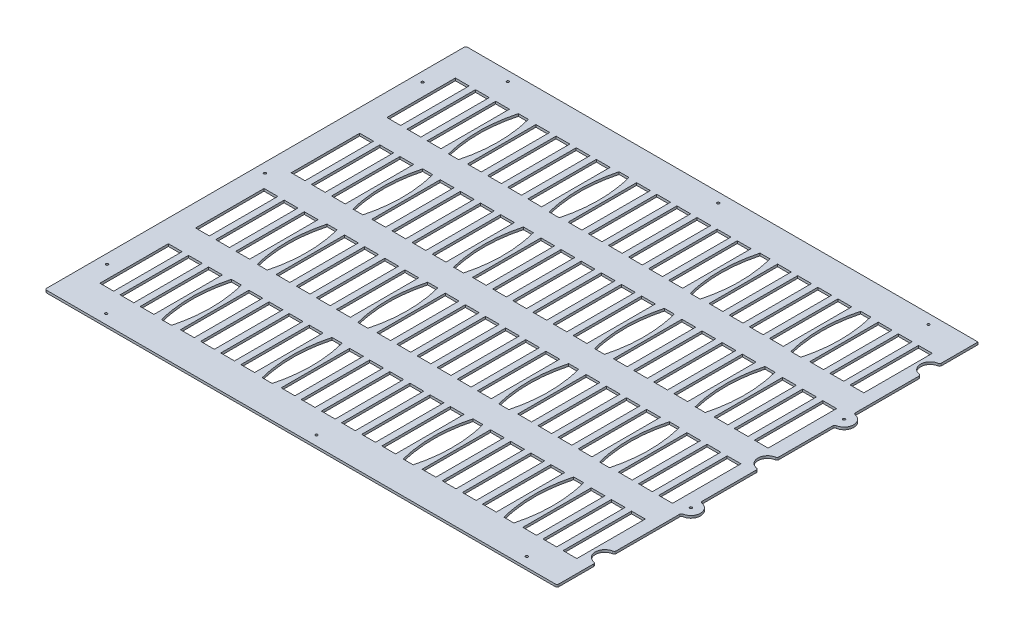
from build123d import *

# Parameters (mm, degrees)
BOSS_EXTRUDE1_DEPTH          = 3.175
SKETCH23_W                   = 18.288
SKETCH23_H                   = 90.932
CUT_EXTRUDE7_DEPTH           = 4.175
LPATTERN1_COUNT              = 24
LPATTERN1_PITCH              = 26.74731252
LPATTERN2_COUNT              = 4
LPATTERN2_PITCH              = 127.0762
LPATTERN2_COPY_1_SKETCH_W    = 18.288
LPATTERN2_COPY_1_SKETCH_H    = 90.932
LPATTERN2_COPY_1_DEPTH       = 4.175
LPATTERN2_COPY_2_SKETCH_W    = 18.288
LPATTERN2_COPY_2_SKETCH_H    = 90.932
LPATTERN2_COPY_2_DEPTH       = 4.175
LPATTERN2_COPY_3_SKETCH_W    = 18.288
LPATTERN2_COPY_3_SKETCH_H    = 90.932
LPATTERN2_COPY_3_DEPTH       = 4.175
LPATTERN2_COPY_4_SKETCH_W    = 18.288
LPATTERN2_COPY_4_SKETCH_H    = 90.932
LPATTERN2_COPY_4_DEPTH       = 4.175
LPATTERN2_COPY_5_SKETCH_W    = 18.288
LPATTERN2_COPY_5_SKETCH_H    = 90.932
LPATTERN2_COPY_5_DEPTH       = 4.175
LPATTERN2_COPY_6_SKETCH_W    = 18.288
LPATTERN2_COPY_6_SKETCH_H    = 90.932
LPATTERN2_COPY_6_DEPTH       = 4.175
LPATTERN2_COPY_7_SKETCH_W    = 18.288
LPATTERN2_COPY_7_SKETCH_H    = 90.932
LPATTERN2_COPY_7_DEPTH       = 4.175
LPATTERN2_COPY_8_SKETCH_W    = 18.288
LPATTERN2_COPY_8_SKETCH_H    = 90.932
LPATTERN2_COPY_8_DEPTH       = 4.175
LPATTERN2_COPY_9_SKETCH_W    = 18.288
LPATTERN2_COPY_9_SKETCH_H    = 90.932
LPATTERN2_COPY_9_DEPTH       = 4.175
LPATTERN2_COPY_10_SKETCH_W   = 18.288
LPATTERN2_COPY_10_SKETCH_H   = 90.932
LPATTERN2_COPY_10_DEPTH      = 4.175
LPATTERN2_COPY_11_SKETCH_W   = 18.288
LPATTERN2_COPY_11_SKETCH_H   = 90.932
LPATTERN2_COPY_11_DEPTH      = 4.175
LPATTERN2_COPY_12_SKETCH_W   = 18.288
LPATTERN2_COPY_12_SKETCH_H   = 90.932
LPATTERN2_COPY_12_DEPTH      = 4.175
LPATTERN2_COPY_13_SKETCH_W   = 18.288
LPATTERN2_COPY_13_SKETCH_H   = 90.932
LPATTERN2_COPY_13_DEPTH      = 4.175
LPATTERN2_COPY_14_SKETCH_W   = 18.288
LPATTERN2_COPY_14_SKETCH_H   = 90.932
LPATTERN2_COPY_14_DEPTH      = 4.175
LPATTERN2_COPY_15_SKETCH_W   = 18.288
LPATTERN2_COPY_15_SKETCH_H   = 90.932
LPATTERN2_COPY_15_DEPTH      = 4.175
LPATTERN2_COPY_16_SKETCH_W   = 18.288
LPATTERN2_COPY_16_SKETCH_H   = 90.932
LPATTERN2_COPY_16_DEPTH      = 4.175
LPATTERN2_COPY_17_SKETCH_W   = 18.288
LPATTERN2_COPY_17_SKETCH_H   = 90.932
LPATTERN2_COPY_17_DEPTH      = 4.175
LPATTERN2_COPY_18_SKETCH_W   = 18.288
LPATTERN2_COPY_18_SKETCH_H   = 90.932
LPATTERN2_COPY_18_DEPTH      = 4.175
LPATTERN2_COPY_19_SKETCH_W   = 18.288
LPATTERN2_COPY_19_SKETCH_H   = 90.932
LPATTERN2_COPY_19_DEPTH      = 4.175
LPATTERN2_COPY_20_SKETCH_W   = 18.288
LPATTERN2_COPY_20_SKETCH_H   = 90.932
LPATTERN2_COPY_20_DEPTH      = 4.175
LPATTERN2_COPY_21_SKETCH_W   = 18.288
LPATTERN2_COPY_21_SKETCH_H   = 90.932
LPATTERN2_COPY_21_DEPTH      = 4.175
LPATTERN2_COPY_22_SKETCH_W   = 18.288
LPATTERN2_COPY_22_SKETCH_H   = 90.932
LPATTERN2_COPY_22_DEPTH      = 4.175
LPATTERN2_COPY_23_SKETCH_W   = 18.288
LPATTERN2_COPY_23_SKETCH_H   = 90.932
LPATTERN2_COPY_23_DEPTH      = 4.175
LPATTERN2_COPY_24_SKETCH_W   = 18.288
LPATTERN2_COPY_24_SKETCH_H   = 90.932
LPATTERN2_COPY_24_DEPTH      = 4.175
LPATTERN2_COPY_25_SKETCH_W   = 18.288
LPATTERN2_COPY_25_SKETCH_H   = 90.932
LPATTERN2_COPY_25_DEPTH      = 4.175
LPATTERN2_COPY_26_SKETCH_W   = 18.288
LPATTERN2_COPY_26_SKETCH_H   = 90.932
LPATTERN2_COPY_26_DEPTH      = 4.175
LPATTERN2_COPY_27_SKETCH_W   = 18.288
LPATTERN2_COPY_27_SKETCH_H   = 90.932
LPATTERN2_COPY_27_DEPTH      = 4.175
LPATTERN2_COPY_28_SKETCH_W   = 18.288
LPATTERN2_COPY_28_SKETCH_H   = 90.932
LPATTERN2_COPY_28_DEPTH      = 4.175
LPATTERN2_COPY_29_SKETCH_W   = 18.288
LPATTERN2_COPY_29_SKETCH_H   = 90.932
LPATTERN2_COPY_29_DEPTH      = 4.175
LPATTERN2_COPY_30_SKETCH_W   = 18.288
LPATTERN2_COPY_30_SKETCH_H   = 90.932
LPATTERN2_COPY_30_DEPTH      = 4.175
LPATTERN2_COPY_31_SKETCH_W   = 18.288
LPATTERN2_COPY_31_SKETCH_H   = 90.932
LPATTERN2_COPY_31_DEPTH      = 4.175
LPATTERN2_COPY_32_SKETCH_W   = 18.288
LPATTERN2_COPY_32_SKETCH_H   = 90.932
LPATTERN2_COPY_32_DEPTH      = 4.175
LPATTERN2_COPY_33_SKETCH_W   = 18.288
LPATTERN2_COPY_33_SKETCH_H   = 90.932
LPATTERN2_COPY_33_DEPTH      = 4.175
LPATTERN2_COPY_34_SKETCH_W   = 18.288
LPATTERN2_COPY_34_SKETCH_H   = 90.932
LPATTERN2_COPY_34_DEPTH      = 4.175
LPATTERN2_COPY_35_SKETCH_W   = 18.288
LPATTERN2_COPY_35_SKETCH_H   = 90.932
LPATTERN2_COPY_35_DEPTH      = 4.175
LPATTERN2_COPY_36_SKETCH_W   = 18.288
LPATTERN2_COPY_36_SKETCH_H   = 90.932
LPATTERN2_COPY_36_DEPTH      = 4.175
LPATTERN2_COPY_37_SKETCH_W   = 18.288
LPATTERN2_COPY_37_SKETCH_H   = 90.932
LPATTERN2_COPY_37_DEPTH      = 4.175
LPATTERN2_COPY_38_SKETCH_W   = 18.288
LPATTERN2_COPY_38_SKETCH_H   = 90.932
LPATTERN2_COPY_38_DEPTH      = 4.175
LPATTERN2_COPY_39_SKETCH_W   = 18.288
LPATTERN2_COPY_39_SKETCH_H   = 90.932
LPATTERN2_COPY_39_DEPTH      = 4.175
LPATTERN2_COPY_40_SKETCH_W   = 18.288
LPATTERN2_COPY_40_SKETCH_H   = 90.932
LPATTERN2_COPY_40_DEPTH      = 4.175
LPATTERN2_COPY_41_SKETCH_W   = 18.288
LPATTERN2_COPY_41_SKETCH_H   = 90.932
LPATTERN2_COPY_41_DEPTH      = 4.175
LPATTERN2_COPY_42_SKETCH_W   = 18.288
LPATTERN2_COPY_42_SKETCH_H   = 90.932
LPATTERN2_COPY_42_DEPTH      = 4.175
LPATTERN2_COPY_43_SKETCH_W   = 18.288
LPATTERN2_COPY_43_SKETCH_H   = 90.932
LPATTERN2_COPY_43_DEPTH      = 4.175
LPATTERN2_COPY_44_SKETCH_W   = 18.288
LPATTERN2_COPY_44_SKETCH_H   = 90.932
LPATTERN2_COPY_44_DEPTH      = 4.175
LPATTERN2_COPY_45_SKETCH_W   = 18.288
LPATTERN2_COPY_45_SKETCH_H   = 90.932
LPATTERN2_COPY_45_DEPTH      = 4.175
LPATTERN2_COPY_46_SKETCH_W   = 18.288
LPATTERN2_COPY_46_SKETCH_H   = 90.932
LPATTERN2_COPY_46_DEPTH      = 4.175
LPATTERN2_COPY_47_SKETCH_W   = 18.288
LPATTERN2_COPY_47_SKETCH_H   = 90.932
LPATTERN2_COPY_47_DEPTH      = 4.175
LPATTERN2_COPY_48_SKETCH_W   = 18.288
LPATTERN2_COPY_48_SKETCH_H   = 90.932
LPATTERN2_COPY_48_DEPTH      = 4.175
LPATTERN2_COPY_49_SKETCH_W   = 18.288
LPATTERN2_COPY_49_SKETCH_H   = 90.932
LPATTERN2_COPY_49_DEPTH      = 4.175
LPATTERN2_COPY_50_SKETCH_W   = 18.288
LPATTERN2_COPY_50_SKETCH_H   = 90.932
LPATTERN2_COPY_50_DEPTH      = 4.175
LPATTERN2_COPY_51_SKETCH_W   = 18.288
LPATTERN2_COPY_51_SKETCH_H   = 90.932
LPATTERN2_COPY_51_DEPTH      = 4.175
LPATTERN2_COPY_52_SKETCH_W   = 18.288
LPATTERN2_COPY_52_SKETCH_H   = 90.932
LPATTERN2_COPY_52_DEPTH      = 4.175
LPATTERN2_COPY_53_SKETCH_W   = 18.288
LPATTERN2_COPY_53_SKETCH_H   = 90.932
LPATTERN2_COPY_53_DEPTH      = 4.175
LPATTERN2_COPY_54_SKETCH_W   = 18.288
LPATTERN2_COPY_54_SKETCH_H   = 90.932
LPATTERN2_COPY_54_DEPTH      = 4.175
LPATTERN2_COPY_55_SKETCH_W   = 18.288
LPATTERN2_COPY_55_SKETCH_H   = 90.932
LPATTERN2_COPY_55_DEPTH      = 4.175
LPATTERN2_COPY_56_SKETCH_W   = 18.288
LPATTERN2_COPY_56_SKETCH_H   = 90.932
LPATTERN2_COPY_56_DEPTH      = 4.175
LPATTERN2_COPY_57_SKETCH_W   = 18.288
LPATTERN2_COPY_57_SKETCH_H   = 90.932
LPATTERN2_COPY_57_DEPTH      = 4.175
CUT_EXTRUDE8_DEPTH           = 4.175
LPATTERN3_COUNT              = 2
LPATTERN3_PITCH              = 320.96775024
LPATTERN3_COUNT_DIR2         = 4
LPATTERN3_PITCH_DIR2         = 127.0762
FILLET1_R                    = 2.54
F_1_8_0_125_DIAMETER_HOLE1_D = 3.175


with BuildPart() as part:
    # Sketch1 → Boss-Extrude1 (new body)
    with BuildSketch(Plane(origin=(0, 0, 0), x_dir=(1, 0, 0), z_dir=(0, 1, 0))):
        with BuildLine():
            Line((-340.1822, -279.5524), (340.1822, -279.5524))
            Line((340.1822, -279.5524), (340.1822, -228.7524))
            ThreePointArc((340.1822, -228.7524), (327.4822, -216.0524), (340.1822, -203.3524))
            Line((340.1822, -203.3524), (340.1822, -114.4524))
            ThreePointArc((340.1822, -114.4524), (352.8822, -101.7524), (340.1822, -89.0524))
            Line((340.1822, -89.0524), (340.1822, -12.7))
            ThreePointArc((340.1822, -12.7), (327.4822, 0), (340.1822, 12.7))
            Line((340.1822, 12.7), (340.1822, 89.0524))
            ThreePointArc((340.1822, 89.0524), (352.8822, 101.7524), (340.1822, 114.4524))
            Line((340.1822, 114.4524), (340.1822, 203.3524))
            ThreePointArc((340.1822, 203.3524), (327.4822, 216.0524), (340.1822, 228.7524))
            Line((340.1822, 228.7524), (340.1822, 279.5524))
            Line((340.1822, 279.5524), (-340.1822, 279.5524))
            Line((-340.1822, 279.5524), (-340.1822, -279.5524))
        make_face()
    extrude(amount=BOSS_EXTRUDE1_DEPTH)

    # Sketch23 → Cut-Extrude7 (cut, through all)
    with BuildSketch(Plane(origin=(0, 3.175, 0), x_dir=(1, 0, 0), z_dir=(0, 1, 0))):
        with Locations((313.7408, -190.5762)):
            Rectangle(SKETCH23_W, SKETCH23_H)
    cut_extrude7 = extrude(amount=-CUT_EXTRUDE7_DEPTH, mode=Mode.SUBTRACT)

    # LPattern1: Cut-Extrude7 ×24, 4 skipped
    with Locations(*[(-i * LPATTERN1_PITCH, 0, 0) for i in range(1, LPATTERN1_COUNT) if i not in (3, 8, 15, 20)]):
        add(cut_extrude7, mode=Mode.SUBTRACT)

    # LPattern2: Cut-Extrude7 ×4
    with Locations(*[(0, 0, -i * LPATTERN2_PITCH) for i in range(1, LPATTERN2_COUNT)]):
        add(cut_extrude7, mode=Mode.SUBTRACT)

    # LPattern2 copy 1 sketch → LPattern2 copy 1 (cut, through all)
    with BuildSketch(Plane(origin=(-26.74731252, 3.175, -127.0762), x_dir=(1, 0, 0), z_dir=(0, 1, 0))):
        with Locations((313.7408, -190.5762)):
            Rectangle(LPATTERN2_COPY_1_SKETCH_W, LPATTERN2_COPY_1_SKETCH_H)
    extrude(amount=-LPATTERN2_COPY_1_DEPTH, mode=Mode.SUBTRACT)

    # LPattern2 copy 2 sketch → LPattern2 copy 2 (cut, through all)
    with BuildSketch(Plane(origin=(-26.74731252, 3.175, -254.1524), x_dir=(1, 0, 0), z_dir=(0, 1, 0))):
        with Locations((313.7408, -190.5762)):
            Rectangle(LPATTERN2_COPY_2_SKETCH_W, LPATTERN2_COPY_2_SKETCH_H)
    extrude(amount=-LPATTERN2_COPY_2_DEPTH, mode=Mode.SUBTRACT)

    # LPattern2 copy 3 sketch → LPattern2 copy 3 (cut, through all)
    with BuildSketch(Plane(origin=(-26.74731252, 3.175, -381.2286), x_dir=(1, 0, 0), z_dir=(0, 1, 0))):
        with Locations((313.7408, -190.5762)):
            Rectangle(LPATTERN2_COPY_3_SKETCH_W, LPATTERN2_COPY_3_SKETCH_H)
    extrude(amount=-LPATTERN2_COPY_3_DEPTH, mode=Mode.SUBTRACT)

    # LPattern2 copy 4 sketch → LPattern2 copy 4 (cut, through all)
    with BuildSketch(Plane(origin=(-53.49462504, 3.175, -127.0762), x_dir=(1, 0, 0), z_dir=(0, 1, 0))):
        with Locations((313.7408, -190.5762)):
            Rectangle(LPATTERN2_COPY_4_SKETCH_W, LPATTERN2_COPY_4_SKETCH_H)
    extrude(amount=-LPATTERN2_COPY_4_DEPTH, mode=Mode.SUBTRACT)

    # LPattern2 copy 5 sketch → LPattern2 copy 5 (cut, through all)
    with BuildSketch(Plane(origin=(-53.49462504, 3.175, -254.1524), x_dir=(1, 0, 0), z_dir=(0, 1, 0))):
        with Locations((313.7408, -190.5762)):
            Rectangle(LPATTERN2_COPY_5_SKETCH_W, LPATTERN2_COPY_5_SKETCH_H)
    extrude(amount=-LPATTERN2_COPY_5_DEPTH, mode=Mode.SUBTRACT)

    # LPattern2 copy 6 sketch → LPattern2 copy 6 (cut, through all)
    with BuildSketch(Plane(origin=(-53.49462504, 3.175, -381.2286), x_dir=(1, 0, 0), z_dir=(0, 1, 0))):
        with Locations((313.7408, -190.5762)):
            Rectangle(LPATTERN2_COPY_6_SKETCH_W, LPATTERN2_COPY_6_SKETCH_H)
    extrude(amount=-LPATTERN2_COPY_6_DEPTH, mode=Mode.SUBTRACT)

    # LPattern2 copy 7 sketch → LPattern2 copy 7 (cut, through all)
    with BuildSketch(Plane(origin=(-106.98925008, 3.175, -127.0762), x_dir=(1, 0, 0), z_dir=(0, 1, 0))):
        with Locations((313.7408, -190.5762)):
            Rectangle(LPATTERN2_COPY_7_SKETCH_W, LPATTERN2_COPY_7_SKETCH_H)
    extrude(amount=-LPATTERN2_COPY_7_DEPTH, mode=Mode.SUBTRACT)

    # LPattern2 copy 8 sketch → LPattern2 copy 8 (cut, through all)
    with BuildSketch(Plane(origin=(-106.98925008, 3.175, -254.1524), x_dir=(1, 0, 0), z_dir=(0, 1, 0))):
        with Locations((313.7408, -190.5762)):
            Rectangle(LPATTERN2_COPY_8_SKETCH_W, LPATTERN2_COPY_8_SKETCH_H)
    extrude(amount=-LPATTERN2_COPY_8_DEPTH, mode=Mode.SUBTRACT)

    # LPattern2 copy 9 sketch → LPattern2 copy 9 (cut, through all)
    with BuildSketch(Plane(origin=(-106.98925008, 3.175, -381.2286), x_dir=(1, 0, 0), z_dir=(0, 1, 0))):
        with Locations((313.7408, -190.5762)):
            Rectangle(LPATTERN2_COPY_9_SKETCH_W, LPATTERN2_COPY_9_SKETCH_H)
    extrude(amount=-LPATTERN2_COPY_9_DEPTH, mode=Mode.SUBTRACT)

    # LPattern2 copy 10 sketch → LPattern2 copy 10 (cut, through all)
    with BuildSketch(Plane(origin=(-133.7365626, 3.175, -127.0762), x_dir=(1, 0, 0), z_dir=(0, 1, 0))):
        with Locations((313.7408, -190.5762)):
            Rectangle(LPATTERN2_COPY_10_SKETCH_W, LPATTERN2_COPY_10_SKETCH_H)
    extrude(amount=-LPATTERN2_COPY_10_DEPTH, mode=Mode.SUBTRACT)

    # LPattern2 copy 11 sketch → LPattern2 copy 11 (cut, through all)
    with BuildSketch(Plane(origin=(-133.7365626, 3.175, -254.1524), x_dir=(1, 0, 0), z_dir=(0, 1, 0))):
        with Locations((313.7408, -190.5762)):
            Rectangle(LPATTERN2_COPY_11_SKETCH_W, LPATTERN2_COPY_11_SKETCH_H)
    extrude(amount=-LPATTERN2_COPY_11_DEPTH, mode=Mode.SUBTRACT)

    # LPattern2 copy 12 sketch → LPattern2 copy 12 (cut, through all)
    with BuildSketch(Plane(origin=(-133.7365626, 3.175, -381.2286), x_dir=(1, 0, 0), z_dir=(0, 1, 0))):
        with Locations((313.7408, -190.5762)):
            Rectangle(LPATTERN2_COPY_12_SKETCH_W, LPATTERN2_COPY_12_SKETCH_H)
    extrude(amount=-LPATTERN2_COPY_12_DEPTH, mode=Mode.SUBTRACT)

    # LPattern2 copy 13 sketch → LPattern2 copy 13 (cut, through all)
    with BuildSketch(Plane(origin=(-160.48387512, 3.175, -127.0762), x_dir=(1, 0, 0), z_dir=(0, 1, 0))):
        with Locations((313.7408, -190.5762)):
            Rectangle(LPATTERN2_COPY_13_SKETCH_W, LPATTERN2_COPY_13_SKETCH_H)
    extrude(amount=-LPATTERN2_COPY_13_DEPTH, mode=Mode.SUBTRACT)

    # LPattern2 copy 14 sketch → LPattern2 copy 14 (cut, through all)
    with BuildSketch(Plane(origin=(-160.48387512, 3.175, -254.1524), x_dir=(1, 0, 0), z_dir=(0, 1, 0))):
        with Locations((313.7408, -190.5762)):
            Rectangle(LPATTERN2_COPY_14_SKETCH_W, LPATTERN2_COPY_14_SKETCH_H)
    extrude(amount=-LPATTERN2_COPY_14_DEPTH, mode=Mode.SUBTRACT)

    # LPattern2 copy 15 sketch → LPattern2 copy 15 (cut, through all)
    with BuildSketch(Plane(origin=(-160.48387512, 3.175, -381.2286), x_dir=(1, 0, 0), z_dir=(0, 1, 0))):
        with Locations((313.7408, -190.5762)):
            Rectangle(LPATTERN2_COPY_15_SKETCH_W, LPATTERN2_COPY_15_SKETCH_H)
    extrude(amount=-LPATTERN2_COPY_15_DEPTH, mode=Mode.SUBTRACT)

    # LPattern2 copy 16 sketch → LPattern2 copy 16 (cut, through all)
    with BuildSketch(Plane(origin=(-187.23118764, 3.175, -127.0762), x_dir=(1, 0, 0), z_dir=(0, 1, 0))):
        with Locations((313.7408, -190.5762)):
            Rectangle(LPATTERN2_COPY_16_SKETCH_W, LPATTERN2_COPY_16_SKETCH_H)
    extrude(amount=-LPATTERN2_COPY_16_DEPTH, mode=Mode.SUBTRACT)

    # LPattern2 copy 17 sketch → LPattern2 copy 17 (cut, through all)
    with BuildSketch(Plane(origin=(-187.23118764, 3.175, -254.1524), x_dir=(1, 0, 0), z_dir=(0, 1, 0))):
        with Locations((313.7408, -190.5762)):
            Rectangle(LPATTERN2_COPY_17_SKETCH_W, LPATTERN2_COPY_17_SKETCH_H)
    extrude(amount=-LPATTERN2_COPY_17_DEPTH, mode=Mode.SUBTRACT)

    # LPattern2 copy 18 sketch → LPattern2 copy 18 (cut, through all)
    with BuildSketch(Plane(origin=(-187.23118764, 3.175, -381.2286), x_dir=(1, 0, 0), z_dir=(0, 1, 0))):
        with Locations((313.7408, -190.5762)):
            Rectangle(LPATTERN2_COPY_18_SKETCH_W, LPATTERN2_COPY_18_SKETCH_H)
    extrude(amount=-LPATTERN2_COPY_18_DEPTH, mode=Mode.SUBTRACT)

    # LPattern2 copy 19 sketch → LPattern2 copy 19 (cut, through all)
    with BuildSketch(Plane(origin=(-240.72581268, 3.175, -127.0762), x_dir=(1, 0, 0), z_dir=(0, 1, 0))):
        with Locations((313.7408, -190.5762)):
            Rectangle(LPATTERN2_COPY_19_SKETCH_W, LPATTERN2_COPY_19_SKETCH_H)
    extrude(amount=-LPATTERN2_COPY_19_DEPTH, mode=Mode.SUBTRACT)

    # LPattern2 copy 20 sketch → LPattern2 copy 20 (cut, through all)
    with BuildSketch(Plane(origin=(-240.72581268, 3.175, -254.1524), x_dir=(1, 0, 0), z_dir=(0, 1, 0))):
        with Locations((313.7408, -190.5762)):
            Rectangle(LPATTERN2_COPY_20_SKETCH_W, LPATTERN2_COPY_20_SKETCH_H)
    extrude(amount=-LPATTERN2_COPY_20_DEPTH, mode=Mode.SUBTRACT)

    # LPattern2 copy 21 sketch → LPattern2 copy 21 (cut, through all)
    with BuildSketch(Plane(origin=(-240.72581268, 3.175, -381.2286), x_dir=(1, 0, 0), z_dir=(0, 1, 0))):
        with Locations((313.7408, -190.5762)):
            Rectangle(LPATTERN2_COPY_21_SKETCH_W, LPATTERN2_COPY_21_SKETCH_H)
    extrude(amount=-LPATTERN2_COPY_21_DEPTH, mode=Mode.SUBTRACT)

    # LPattern2 copy 22 sketch → LPattern2 copy 22 (cut, through all)
    with BuildSketch(Plane(origin=(-267.4731252, 3.175, -127.0762), x_dir=(1, 0, 0), z_dir=(0, 1, 0))):
        with Locations((313.7408, -190.5762)):
            Rectangle(LPATTERN2_COPY_22_SKETCH_W, LPATTERN2_COPY_22_SKETCH_H)
    extrude(amount=-LPATTERN2_COPY_22_DEPTH, mode=Mode.SUBTRACT)

    # LPattern2 copy 23 sketch → LPattern2 copy 23 (cut, through all)
    with BuildSketch(Plane(origin=(-267.4731252, 3.175, -254.1524), x_dir=(1, 0, 0), z_dir=(0, 1, 0))):
        with Locations((313.7408, -190.5762)):
            Rectangle(LPATTERN2_COPY_23_SKETCH_W, LPATTERN2_COPY_23_SKETCH_H)
    extrude(amount=-LPATTERN2_COPY_23_DEPTH, mode=Mode.SUBTRACT)

    # LPattern2 copy 24 sketch → LPattern2 copy 24 (cut, through all)
    with BuildSketch(Plane(origin=(-267.4731252, 3.175, -381.2286), x_dir=(1, 0, 0), z_dir=(0, 1, 0))):
        with Locations((313.7408, -190.5762)):
            Rectangle(LPATTERN2_COPY_24_SKETCH_W, LPATTERN2_COPY_24_SKETCH_H)
    extrude(amount=-LPATTERN2_COPY_24_DEPTH, mode=Mode.SUBTRACT)

    # LPattern2 copy 25 sketch → LPattern2 copy 25 (cut, through all)
    with BuildSketch(Plane(origin=(-294.22043772, 3.175, -127.0762), x_dir=(1, 0, 0), z_dir=(0, 1, 0))):
        with Locations((313.7408, -190.5762)):
            Rectangle(LPATTERN2_COPY_25_SKETCH_W, LPATTERN2_COPY_25_SKETCH_H)
    extrude(amount=-LPATTERN2_COPY_25_DEPTH, mode=Mode.SUBTRACT)

    # LPattern2 copy 26 sketch → LPattern2 copy 26 (cut, through all)
    with BuildSketch(Plane(origin=(-294.22043772, 3.175, -254.1524), x_dir=(1, 0, 0), z_dir=(0, 1, 0))):
        with Locations((313.7408, -190.5762)):
            Rectangle(LPATTERN2_COPY_26_SKETCH_W, LPATTERN2_COPY_26_SKETCH_H)
    extrude(amount=-LPATTERN2_COPY_26_DEPTH, mode=Mode.SUBTRACT)

    # LPattern2 copy 27 sketch → LPattern2 copy 27 (cut, through all)
    with BuildSketch(Plane(origin=(-294.22043772, 3.175, -381.2286), x_dir=(1, 0, 0), z_dir=(0, 1, 0))):
        with Locations((313.7408, -190.5762)):
            Rectangle(LPATTERN2_COPY_27_SKETCH_W, LPATTERN2_COPY_27_SKETCH_H)
    extrude(amount=-LPATTERN2_COPY_27_DEPTH, mode=Mode.SUBTRACT)

    # LPattern2 copy 28 sketch → LPattern2 copy 28 (cut, through all)
    with BuildSketch(Plane(origin=(-320.96775024, 3.175, -127.0762), x_dir=(1, 0, 0), z_dir=(0, 1, 0))):
        with Locations((313.7408, -190.5762)):
            Rectangle(LPATTERN2_COPY_28_SKETCH_W, LPATTERN2_COPY_28_SKETCH_H)
    extrude(amount=-LPATTERN2_COPY_28_DEPTH, mode=Mode.SUBTRACT)

    # LPattern2 copy 29 sketch → LPattern2 copy 29 (cut, through all)
    with BuildSketch(Plane(origin=(-320.96775024, 3.175, -254.1524), x_dir=(1, 0, 0), z_dir=(0, 1, 0))):
        with Locations((313.7408, -190.5762)):
            Rectangle(LPATTERN2_COPY_29_SKETCH_W, LPATTERN2_COPY_29_SKETCH_H)
    extrude(amount=-LPATTERN2_COPY_29_DEPTH, mode=Mode.SUBTRACT)

    # LPattern2 copy 30 sketch → LPattern2 copy 30 (cut, through all)
    with BuildSketch(Plane(origin=(-320.96775024, 3.175, -381.2286), x_dir=(1, 0, 0), z_dir=(0, 1, 0))):
        with Locations((313.7408, -190.5762)):
            Rectangle(LPATTERN2_COPY_30_SKETCH_W, LPATTERN2_COPY_30_SKETCH_H)
    extrude(amount=-LPATTERN2_COPY_30_DEPTH, mode=Mode.SUBTRACT)

    # LPattern2 copy 31 sketch → LPattern2 copy 31 (cut, through all)
    with BuildSketch(Plane(origin=(-347.71506276, 3.175, -127.0762), x_dir=(1, 0, 0), z_dir=(0, 1, 0))):
        with Locations((313.7408, -190.5762)):
            Rectangle(LPATTERN2_COPY_31_SKETCH_W, LPATTERN2_COPY_31_SKETCH_H)
    extrude(amount=-LPATTERN2_COPY_31_DEPTH, mode=Mode.SUBTRACT)

    # LPattern2 copy 32 sketch → LPattern2 copy 32 (cut, through all)
    with BuildSketch(Plane(origin=(-347.71506276, 3.175, -254.1524), x_dir=(1, 0, 0), z_dir=(0, 1, 0))):
        with Locations((313.7408, -190.5762)):
            Rectangle(LPATTERN2_COPY_32_SKETCH_W, LPATTERN2_COPY_32_SKETCH_H)
    extrude(amount=-LPATTERN2_COPY_32_DEPTH, mode=Mode.SUBTRACT)

    # LPattern2 copy 33 sketch → LPattern2 copy 33 (cut, through all)
    with BuildSketch(Plane(origin=(-347.71506276, 3.175, -381.2286), x_dir=(1, 0, 0), z_dir=(0, 1, 0))):
        with Locations((313.7408, -190.5762)):
            Rectangle(LPATTERN2_COPY_33_SKETCH_W, LPATTERN2_COPY_33_SKETCH_H)
    extrude(amount=-LPATTERN2_COPY_33_DEPTH, mode=Mode.SUBTRACT)

    # LPattern2 copy 34 sketch → LPattern2 copy 34 (cut, through all)
    with BuildSketch(Plane(origin=(-374.46237528, 3.175, -127.0762), x_dir=(1, 0, 0), z_dir=(0, 1, 0))):
        with Locations((313.7408, -190.5762)):
            Rectangle(LPATTERN2_COPY_34_SKETCH_W, LPATTERN2_COPY_34_SKETCH_H)
    extrude(amount=-LPATTERN2_COPY_34_DEPTH, mode=Mode.SUBTRACT)

    # LPattern2 copy 35 sketch → LPattern2 copy 35 (cut, through all)
    with BuildSketch(Plane(origin=(-374.46237528, 3.175, -254.1524), x_dir=(1, 0, 0), z_dir=(0, 1, 0))):
        with Locations((313.7408, -190.5762)):
            Rectangle(LPATTERN2_COPY_35_SKETCH_W, LPATTERN2_COPY_35_SKETCH_H)
    extrude(amount=-LPATTERN2_COPY_35_DEPTH, mode=Mode.SUBTRACT)

    # LPattern2 copy 36 sketch → LPattern2 copy 36 (cut, through all)
    with BuildSketch(Plane(origin=(-374.46237528, 3.175, -381.2286), x_dir=(1, 0, 0), z_dir=(0, 1, 0))):
        with Locations((313.7408, -190.5762)):
            Rectangle(LPATTERN2_COPY_36_SKETCH_W, LPATTERN2_COPY_36_SKETCH_H)
    extrude(amount=-LPATTERN2_COPY_36_DEPTH, mode=Mode.SUBTRACT)

    # LPattern2 copy 37 sketch → LPattern2 copy 37 (cut, through all)
    with BuildSketch(Plane(origin=(-427.95700032, 3.175, -127.0762), x_dir=(1, 0, 0), z_dir=(0, 1, 0))):
        with Locations((313.7408, -190.5762)):
            Rectangle(LPATTERN2_COPY_37_SKETCH_W, LPATTERN2_COPY_37_SKETCH_H)
    extrude(amount=-LPATTERN2_COPY_37_DEPTH, mode=Mode.SUBTRACT)

    # LPattern2 copy 38 sketch → LPattern2 copy 38 (cut, through all)
    with BuildSketch(Plane(origin=(-427.95700032, 3.175, -254.1524), x_dir=(1, 0, 0), z_dir=(0, 1, 0))):
        with Locations((313.7408, -190.5762)):
            Rectangle(LPATTERN2_COPY_38_SKETCH_W, LPATTERN2_COPY_38_SKETCH_H)
    extrude(amount=-LPATTERN2_COPY_38_DEPTH, mode=Mode.SUBTRACT)

    # LPattern2 copy 39 sketch → LPattern2 copy 39 (cut, through all)
    with BuildSketch(Plane(origin=(-427.95700032, 3.175, -381.2286), x_dir=(1, 0, 0), z_dir=(0, 1, 0))):
        with Locations((313.7408, -190.5762)):
            Rectangle(LPATTERN2_COPY_39_SKETCH_W, LPATTERN2_COPY_39_SKETCH_H)
    extrude(amount=-LPATTERN2_COPY_39_DEPTH, mode=Mode.SUBTRACT)

    # LPattern2 copy 40 sketch → LPattern2 copy 40 (cut, through all)
    with BuildSketch(Plane(origin=(-454.70431284, 3.175, -127.0762), x_dir=(1, 0, 0), z_dir=(0, 1, 0))):
        with Locations((313.7408, -190.5762)):
            Rectangle(LPATTERN2_COPY_40_SKETCH_W, LPATTERN2_COPY_40_SKETCH_H)
    extrude(amount=-LPATTERN2_COPY_40_DEPTH, mode=Mode.SUBTRACT)

    # LPattern2 copy 41 sketch → LPattern2 copy 41 (cut, through all)
    with BuildSketch(Plane(origin=(-454.70431284, 3.175, -254.1524), x_dir=(1, 0, 0), z_dir=(0, 1, 0))):
        with Locations((313.7408, -190.5762)):
            Rectangle(LPATTERN2_COPY_41_SKETCH_W, LPATTERN2_COPY_41_SKETCH_H)
    extrude(amount=-LPATTERN2_COPY_41_DEPTH, mode=Mode.SUBTRACT)

    # LPattern2 copy 42 sketch → LPattern2 copy 42 (cut, through all)
    with BuildSketch(Plane(origin=(-454.70431284, 3.175, -381.2286), x_dir=(1, 0, 0), z_dir=(0, 1, 0))):
        with Locations((313.7408, -190.5762)):
            Rectangle(LPATTERN2_COPY_42_SKETCH_W, LPATTERN2_COPY_42_SKETCH_H)
    extrude(amount=-LPATTERN2_COPY_42_DEPTH, mode=Mode.SUBTRACT)

    # LPattern2 copy 43 sketch → LPattern2 copy 43 (cut, through all)
    with BuildSketch(Plane(origin=(-481.45162536, 3.175, -127.0762), x_dir=(1, 0, 0), z_dir=(0, 1, 0))):
        with Locations((313.7408, -190.5762)):
            Rectangle(LPATTERN2_COPY_43_SKETCH_W, LPATTERN2_COPY_43_SKETCH_H)
    extrude(amount=-LPATTERN2_COPY_43_DEPTH, mode=Mode.SUBTRACT)

    # LPattern2 copy 44 sketch → LPattern2 copy 44 (cut, through all)
    with BuildSketch(Plane(origin=(-481.45162536, 3.175, -254.1524), x_dir=(1, 0, 0), z_dir=(0, 1, 0))):
        with Locations((313.7408, -190.5762)):
            Rectangle(LPATTERN2_COPY_44_SKETCH_W, LPATTERN2_COPY_44_SKETCH_H)
    extrude(amount=-LPATTERN2_COPY_44_DEPTH, mode=Mode.SUBTRACT)

    # LPattern2 copy 45 sketch → LPattern2 copy 45 (cut, through all)
    with BuildSketch(Plane(origin=(-481.45162536, 3.175, -381.2286), x_dir=(1, 0, 0), z_dir=(0, 1, 0))):
        with Locations((313.7408, -190.5762)):
            Rectangle(LPATTERN2_COPY_45_SKETCH_W, LPATTERN2_COPY_45_SKETCH_H)
    extrude(amount=-LPATTERN2_COPY_45_DEPTH, mode=Mode.SUBTRACT)

    # LPattern2 copy 46 sketch → LPattern2 copy 46 (cut, through all)
    with BuildSketch(Plane(origin=(-508.19893788, 3.175, -127.0762), x_dir=(1, 0, 0), z_dir=(0, 1, 0))):
        with Locations((313.7408, -190.5762)):
            Rectangle(LPATTERN2_COPY_46_SKETCH_W, LPATTERN2_COPY_46_SKETCH_H)
    extrude(amount=-LPATTERN2_COPY_46_DEPTH, mode=Mode.SUBTRACT)

    # LPattern2 copy 47 sketch → LPattern2 copy 47 (cut, through all)
    with BuildSketch(Plane(origin=(-508.19893788, 3.175, -254.1524), x_dir=(1, 0, 0), z_dir=(0, 1, 0))):
        with Locations((313.7408, -190.5762)):
            Rectangle(LPATTERN2_COPY_47_SKETCH_W, LPATTERN2_COPY_47_SKETCH_H)
    extrude(amount=-LPATTERN2_COPY_47_DEPTH, mode=Mode.SUBTRACT)

    # LPattern2 copy 48 sketch → LPattern2 copy 48 (cut, through all)
    with BuildSketch(Plane(origin=(-508.19893788, 3.175, -381.2286), x_dir=(1, 0, 0), z_dir=(0, 1, 0))):
        with Locations((313.7408, -190.5762)):
            Rectangle(LPATTERN2_COPY_48_SKETCH_W, LPATTERN2_COPY_48_SKETCH_H)
    extrude(amount=-LPATTERN2_COPY_48_DEPTH, mode=Mode.SUBTRACT)

    # LPattern2 copy 49 sketch → LPattern2 copy 49 (cut, through all)
    with BuildSketch(Plane(origin=(-561.69356292, 3.175, -127.0762), x_dir=(1, 0, 0), z_dir=(0, 1, 0))):
        with Locations((313.7408, -190.5762)):
            Rectangle(LPATTERN2_COPY_49_SKETCH_W, LPATTERN2_COPY_49_SKETCH_H)
    extrude(amount=-LPATTERN2_COPY_49_DEPTH, mode=Mode.SUBTRACT)

    # LPattern2 copy 50 sketch → LPattern2 copy 50 (cut, through all)
    with BuildSketch(Plane(origin=(-561.69356292, 3.175, -254.1524), x_dir=(1, 0, 0), z_dir=(0, 1, 0))):
        with Locations((313.7408, -190.5762)):
            Rectangle(LPATTERN2_COPY_50_SKETCH_W, LPATTERN2_COPY_50_SKETCH_H)
    extrude(amount=-LPATTERN2_COPY_50_DEPTH, mode=Mode.SUBTRACT)

    # LPattern2 copy 51 sketch → LPattern2 copy 51 (cut, through all)
    with BuildSketch(Plane(origin=(-561.69356292, 3.175, -381.2286), x_dir=(1, 0, 0), z_dir=(0, 1, 0))):
        with Locations((313.7408, -190.5762)):
            Rectangle(LPATTERN2_COPY_51_SKETCH_W, LPATTERN2_COPY_51_SKETCH_H)
    extrude(amount=-LPATTERN2_COPY_51_DEPTH, mode=Mode.SUBTRACT)

    # LPattern2 copy 52 sketch → LPattern2 copy 52 (cut, through all)
    with BuildSketch(Plane(origin=(-588.44087544, 3.175, -127.0762), x_dir=(1, 0, 0), z_dir=(0, 1, 0))):
        with Locations((313.7408, -190.5762)):
            Rectangle(LPATTERN2_COPY_52_SKETCH_W, LPATTERN2_COPY_52_SKETCH_H)
    extrude(amount=-LPATTERN2_COPY_52_DEPTH, mode=Mode.SUBTRACT)

    # LPattern2 copy 53 sketch → LPattern2 copy 53 (cut, through all)
    with BuildSketch(Plane(origin=(-588.44087544, 3.175, -254.1524), x_dir=(1, 0, 0), z_dir=(0, 1, 0))):
        with Locations((313.7408, -190.5762)):
            Rectangle(LPATTERN2_COPY_53_SKETCH_W, LPATTERN2_COPY_53_SKETCH_H)
    extrude(amount=-LPATTERN2_COPY_53_DEPTH, mode=Mode.SUBTRACT)

    # LPattern2 copy 54 sketch → LPattern2 copy 54 (cut, through all)
    with BuildSketch(Plane(origin=(-588.44087544, 3.175, -381.2286), x_dir=(1, 0, 0), z_dir=(0, 1, 0))):
        with Locations((313.7408, -190.5762)):
            Rectangle(LPATTERN2_COPY_54_SKETCH_W, LPATTERN2_COPY_54_SKETCH_H)
    extrude(amount=-LPATTERN2_COPY_54_DEPTH, mode=Mode.SUBTRACT)

    # LPattern2 copy 55 sketch → LPattern2 copy 55 (cut, through all)
    with BuildSketch(Plane(origin=(-615.18818796, 3.175, -127.0762), x_dir=(1, 0, 0), z_dir=(0, 1, 0))):
        with Locations((313.7408, -190.5762)):
            Rectangle(LPATTERN2_COPY_55_SKETCH_W, LPATTERN2_COPY_55_SKETCH_H)
    extrude(amount=-LPATTERN2_COPY_55_DEPTH, mode=Mode.SUBTRACT)

    # LPattern2 copy 56 sketch → LPattern2 copy 56 (cut, through all)
    with BuildSketch(Plane(origin=(-615.18818796, 3.175, -254.1524), x_dir=(1, 0, 0), z_dir=(0, 1, 0))):
        with Locations((313.7408, -190.5762)):
            Rectangle(LPATTERN2_COPY_56_SKETCH_W, LPATTERN2_COPY_56_SKETCH_H)
    extrude(amount=-LPATTERN2_COPY_56_DEPTH, mode=Mode.SUBTRACT)

    # LPattern2 copy 57 sketch → LPattern2 copy 57 (cut, through all)
    with BuildSketch(Plane(origin=(-615.18818796, 3.175, -381.2286), x_dir=(1, 0, 0), z_dir=(0, 1, 0))):
        with Locations((313.7408, -190.5762)):
            Rectangle(LPATTERN2_COPY_57_SKETCH_W, LPATTERN2_COPY_57_SKETCH_H)
    extrude(amount=-LPATTERN2_COPY_57_DEPTH, mode=Mode.SUBTRACT)

    # Sketch24 → Cut-Extrude8 (cut, through all)
    with BuildSketch(Plane(origin=(0, 3.175, 0), x_dir=(1, 0, 0), z_dir=(0, 1, 0))):
        with BuildLine():
            Line((240.10286244, -144.2212), (226.89486244, -144.2212))
            add(Edge.make_bspline(
                [(226.89486244, -236.9312), (214.70286244, -190.5762), (226.89486244, -144.2212)],
                knots=[0, 0, 0, 1, 1, 1], degree=2))
            Line((226.89486244, -236.9312), (240.10286244, -236.9312))
            add(Edge.make_bspline(
                [(240.10286244, -236.9312), (252.29486244, -190.5762), (240.10286244, -144.2212)],
                knots=[0, 0, 0, 1, 1, 1], degree=2))
        make_face()
        with BuildLine():
            Line((106.36629984, -236.9312), (93.15829984, -236.9312))
            add(Edge.make_bspline(
                [(93.15829984, -236.9312), (80.96629984, -190.5762), (93.15829984, -144.2212)],
                knots=[0, 0, 0, 1, 1, 1], degree=2))
            Line((93.15829984, -144.2212), (106.36629984, -144.2212))
            add(Edge.make_bspline(
                [(106.36629984, -236.9312), (118.55829984, -190.5762), (106.36629984, -144.2212)],
                knots=[0, 0, 0, 1, 1, 1], degree=2))
        make_face()
    cut_extrude8 = extrude(amount=-CUT_EXTRUDE8_DEPTH, mode=Mode.SUBTRACT)

    # LPattern3: Cut-Extrude8 2 × 4
    with Locations(*[(-i * LPATTERN3_PITCH, 0, -j * LPATTERN3_PITCH_DIR2) for i in range(LPATTERN3_COUNT) for j in range(LPATTERN3_COUNT_DIR2) if (i, j) != (0, 0)]):
        add(cut_extrude8, mode=Mode.SUBTRACT)

    # Fillet1
    fillet1_edges = [part.edges().sort_by_distance(p)[0] for p in [
        (-340.1822, 1.5875, -279.5524),
        (340.1822, 1.5875, -228.7524),
        (340.1822, 1.5875, -203.3524),
        (340.1822, 1.5875, -114.4524),
        (340.1822, 1.5875, -89.0524),
        (340.1822, 1.5875, -12.7),
        (340.1822, 1.5875, 12.7),
        (340.1822, 1.5875, 89.0524),
        (340.1822, 1.5875, 114.4524),
        (340.1822, 1.5875, 203.3524),
        (340.1822, 1.5875, 228.7524),
        (340.1822, 1.5875, 279.5524),
        (-340.1822, 1.5875, 279.5524),
    ]]
    fillet(fillet1_edges, radius=FILLET1_R)

    # 1/8 (0.125) Diameter Hole1 (through all)
    with Locations(Plane(origin=(0, 3.175, 0), x_dir=(1, 0, 0), z_dir=(0, 1, 0))):
        with Locations((287.274, -266.8524), (287.274, 266.8524), (7.874, 266.8524), (-271.526, 266.8524), (-327.5584, 209.55), (-327.5584, 0), (-327.5584, -209.55), (-271.526, -266.8524), (7.874, -266.8524), (340.1822, 101.7524), (340.1822, -101.7524)):
            Hole(F_1_8_0_125_DIAMETER_HOLE1_D / 2)


solid = part.part
